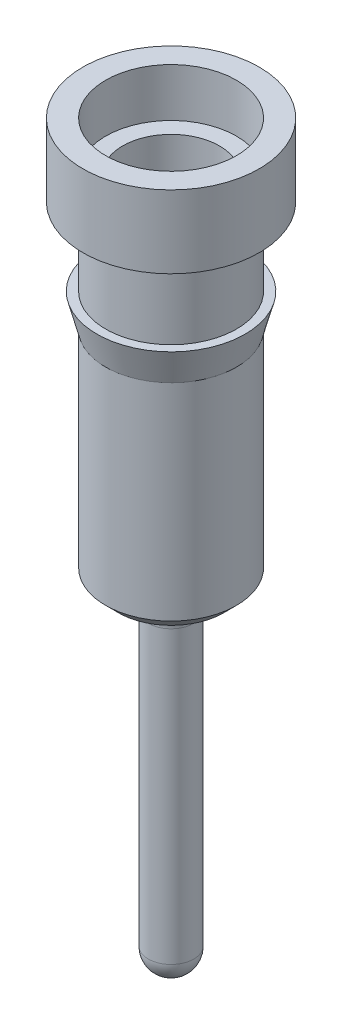
from build123d import *

# Parameters (mm, degrees)
DOME1_FACE_RADIUS = 0.5
DOME1_HEIGHT      = 0.235
DOME2_FACE_RADIUS = 0.235
DOME2_HEIGHT      = 0.235
FILLET1_R         = 0.25


with BuildPart() as part:
    # Sketch1 → Revolve1 (revolve)
    with BuildSketch(Plane.XY):
        Polygon((0, 0), (0, 3.75), (0.5, 3.75), (0.5, 6.9), (0.675, 6.9), (0.675, 7.4), (0.91, 7.4), (0.91, 6.65), (0.675, 6.65), (0.675, 5.85), (0.765, 5.85), (0.675, 5.51), (0.675, 3.38), (0.545, 3.25), (0.235, 3.25), (0.235, 0), align=None)
    revolve(axis=Axis((0, 0, 0), (0, 1, 0)))

    # Dome1: a dome of height H over a round flat face of radius A is a cap of a sphere of radius (A * A + H * H) / (2 * H)
    dome1_r = (DOME1_FACE_RADIUS * DOME1_FACE_RADIUS + DOME1_HEIGHT * DOME1_HEIGHT) / (2 * DOME1_HEIGHT)
    dome1_base = Plane((0, 3.75, 0), z_dir=(0, 1, 0))
    with Locations(dome1_base.offset(DOME1_HEIGHT - dome1_r)):
        dome1_ball = Sphere(dome1_r, mode=Mode.PRIVATE)
    add(split(dome1_ball, bisect_by=dome1_base, keep=Keep.TOP, mode=Mode.PRIVATE))

    # Dome2: a dome of height H over a round flat face of radius A is a cap of a sphere of radius (A * A + H * H) / (2 * H)
    dome2_r = (DOME2_FACE_RADIUS * DOME2_FACE_RADIUS + DOME2_HEIGHT * DOME2_HEIGHT) / (2 * DOME2_HEIGHT)
    dome2_base = Plane((0, 0, 0), z_dir=(0, -1, 0))
    with Locations(dome2_base.offset(DOME2_HEIGHT - dome2_r)):
        dome2_ball = Sphere(dome2_r, mode=Mode.PRIVATE)
    add(split(dome2_ball, bisect_by=dome2_base, keep=Keep.TOP, mode=Mode.PRIVATE))

    # Fillet1
    fillet1_edges = [part.edges().sort_by_distance(p)[0] for p in [
        (-0.235, 3.25, 0),
    ]]
    fillet(fillet1_edges, radius=FILLET1_R)


solid = part.part
